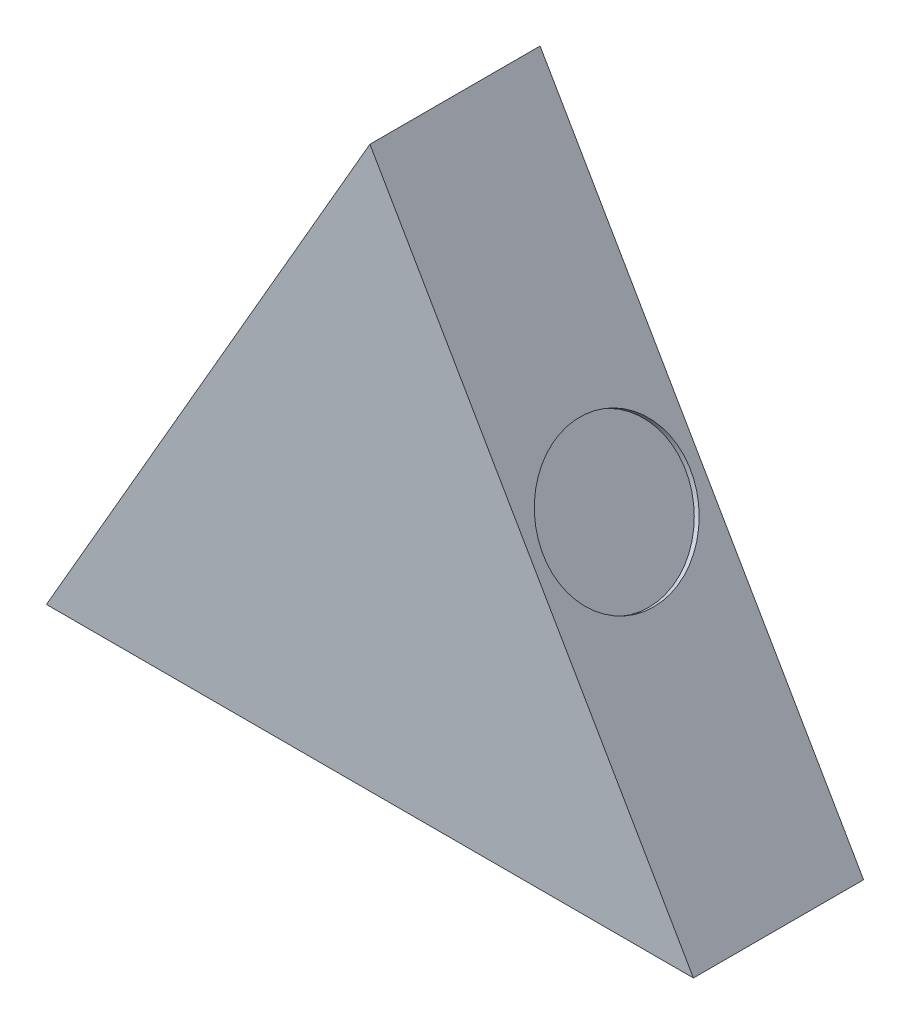
from build123d import *

# Parameters (mm, degrees)
EXTRUDE_2_DEPTH     = 15
CUT_EXTRUDE_2_DEPTH = 13
SKETCH_5_R          = 6.5
CUT_EXTRUDE_3_DEPTH = 0.5
SKETCH_6_R          = 6.5
CUT_EXTRUDE_5_DEPTH = 0.5
SKETCH_7_R          = 6.5
CUT_EXTRUDE_8_DEPTH = 0.5


with BuildPart() as part:
    # 草图1 → 凸台-拉伸2 (new body)
    with BuildSketch(Plane.XY):
        Polygon((0, 24.697120967), (-28.517778878, -24.697120967), (28.517778878, -24.697120967), align=None)
    extrude(amount=EXTRUDE_2_DEPTH)

    # 草图4 → 切除-拉伸2 (cut)
    with BuildSketch(Plane.XY):
        with BuildLine():
            Line((-13.473817403, -3.562999264), (-13.473817403, -20.062999264))
            ThreePointArc((-13.473817403, -20.062999264), (-12.456359842, -22.519359106), (-10, -23.536816667))
            Line((-10, -23.536816667), (10, -23.536816667))
            ThreePointArc((10, -23.536816667), (12.456359842, -22.519359106), (13.473817403, -20.062999264))
            Line((13.473817403, -20.062999264), (13.473817403, -3.562999264))
            ThreePointArc((13.473817403, -3.562999264), (10.667568819, 4.667840965), (3.417761445, 9.470137814))
            Line((3.417761445, 9.470137814), (2.376312346, 9.700444286))
            ThreePointArc((2.376312346, 9.700444286), (0, 10.502453106), (-2.376312346, 9.700444286))
            Line((-2.376312346, 9.700444286), (-3.417761445, 9.470137814))
            ThreePointArc((-3.417761445, 9.470137814), (-10.667568819, 4.667840965), (-13.473817403, -3.562999264))
        make_face()
    extrude(amount=CUT_EXTRUDE_2_DEPTH, mode=Mode.SUBTRACT)

    # 草图5 → 切除-拉伸3 (cut)
    with BuildSketch(Plane.XZ.offset(24.697120967)):
        with Locations((0, 7.5)):
            Circle(SKETCH_5_R)
    extrude(amount=-CUT_EXTRUDE_3_DEPTH, mode=Mode.SUBTRACT)

    # 草图6 → 切除-拉伸5 (cut)
    with BuildSketch(Plane(origin=(-14.258889439, 0, 0), x_dir=(0.5, 0.866025404, 0), z_dir=(0.866025404, -0.5, 0))):
        with Locations((0, 7.5)):
            Circle(SKETCH_6_R)
    extrude(amount=CUT_EXTRUDE_5_DEPTH, mode=Mode.SUBTRACT)

    # 草图7 → 切除-拉伸8 (cut)
    with BuildSketch(Plane(origin=(14.258889439, 0, 0), x_dir=(0.5, -0.866025404, 0), z_dir=(-0.866025404, -0.5, 0))):
        with Locations((0, 7.5)):
            Circle(SKETCH_7_R)
    extrude(amount=CUT_EXTRUDE_8_DEPTH, mode=Mode.SUBTRACT)


solid = part.part
